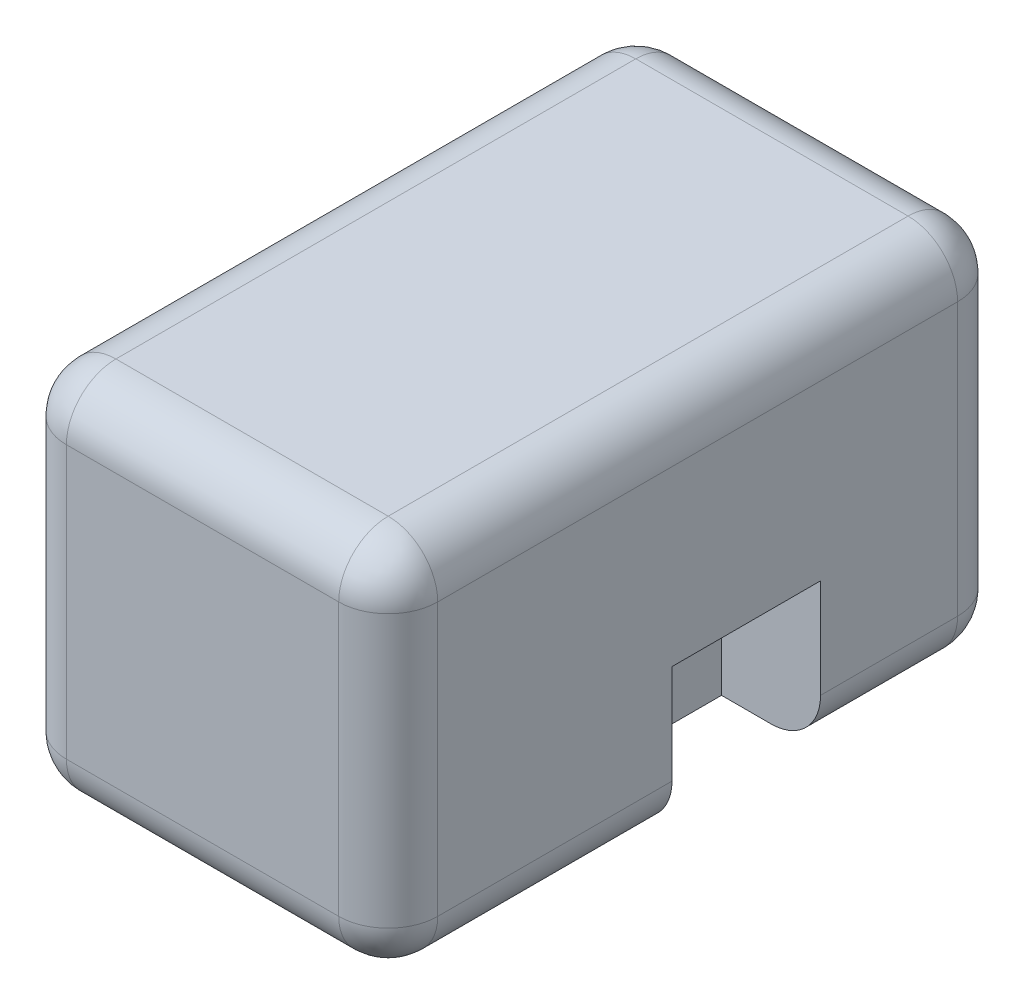
from build123d import *

# Parameters (mm, degrees)
ESQUISSE1_W             = 150
ESQUISSE1_H             = 150
BOSS_EXTRU_1_DEPTH      = 250
CONG_1_R                = 20
ESQUISSE2_W             = 60
ESQUISSE2_H             = 80
ENL_V_MAT_EXTRU_1_DEPTH = 40
ESQUISSE4_W             = 60
ESQUISSE4_H             = 60
ENL_V_MAT_EXTRU_2_DEPTH = 40


with BuildPart() as part:
    # Esquisse1 → Boss.-Extru.1 (new body)
    with BuildSketch(Plane.XY):
        with Locations((75, 75)):
            Rectangle(ESQUISSE1_W, ESQUISSE1_H)
    extrude(amount=BOSS_EXTRU_1_DEPTH)

    # Congé1
    cong_1_edges = [part.edges().sort_by_distance(p)[0] for p in [
        (150, 75, 250),
        (75, 150, 250),
        (0, 75, 250),
        (75, 150, 0),
        (150, 75, 0),
        (75, 0, 0),
        (0, 75, 0),
        (0, 150, 125),
        (150, 150, 125),
        (150, 0, 125),
        (0, 0, 125),
        (75, 0, 250),
    ]]
    fillet(cong_1_edges, radius=CONG_1_R)

    # Esquisse2 → Enlèv. mat.-Extru.1 (cut)
    with BuildSketch(Plane(origin=(150, 0, 0), x_dir=(0, 0, -1), z_dir=(1, 0, 0))):
        with Locations((-105.364762055, 20.069300744)):
            Rectangle(ESQUISSE2_W, ESQUISSE2_H)
    extrude(amount=-ENL_V_MAT_EXTRU_1_DEPTH, mode=Mode.SUBTRACT)

    # Esquisse4 → Enlèv. mat.-Extru.2 (cut)
    with BuildSketch(Plane.ZY):
        with Locations((105.517882432, 30)):
            Rectangle(ESQUISSE4_W, ESQUISSE4_H)
    extrude(amount=-ENL_V_MAT_EXTRU_2_DEPTH, mode=Mode.SUBTRACT)


solid = part.part
